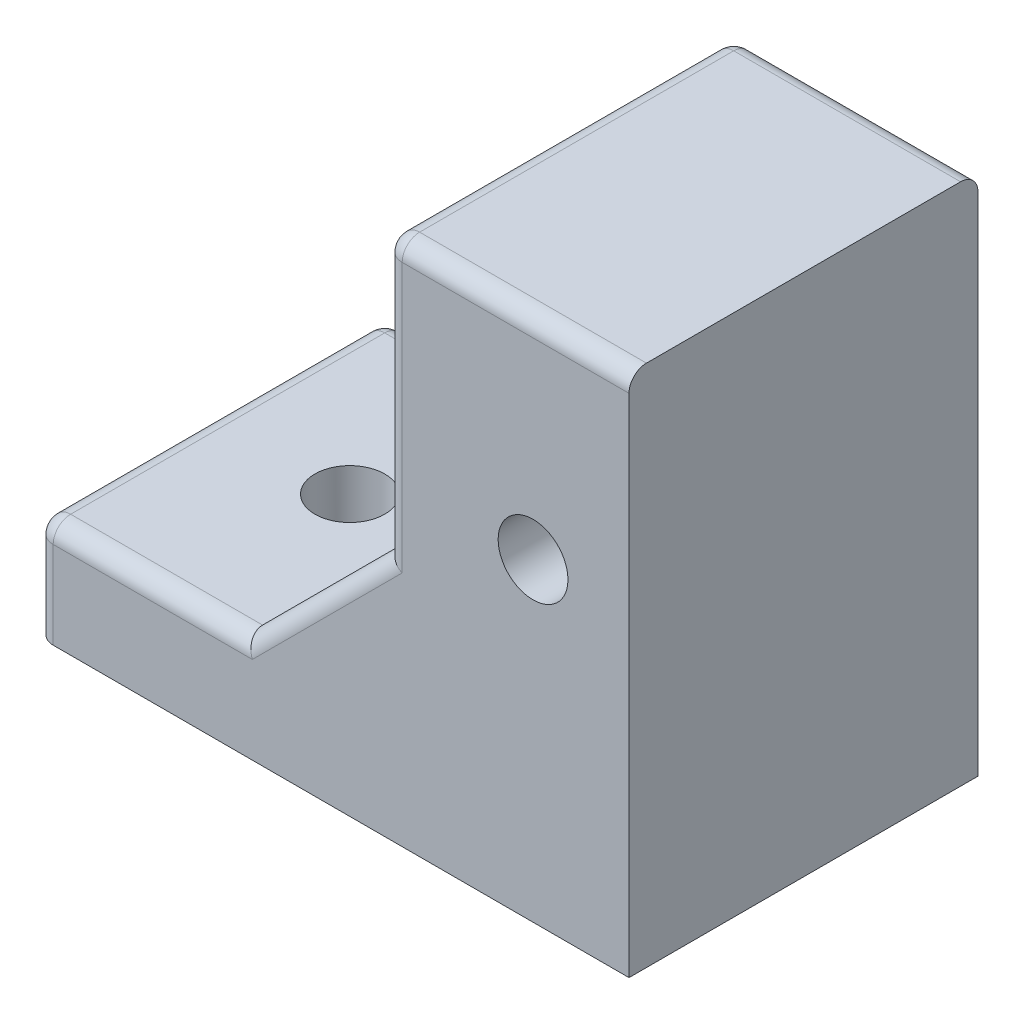
from build123d import *

# Parameters (mm, degrees)
ESQUISSE2_W                  = 7
ESQUISSE2_H                  = 10
BOSS_EXTRU_1_DEPTH           = 15
ESQUISSE3_W                  = 10
ESQUISSE3_H                  = 3
BOSS_EXTRU_2_DEPTH           = 10
BOSS_EXTRU_3_DEPTH           = 2
ESQUISSE7_R                  = 1
ENL_V_MAT_EXTRU_1_DEPTH      = 13
ENL_V_MAT_EXTRU_1_DEPTH_BACK = 4
ESQUISSE8_R                  = 1
ENL_V_MAT_EXTRU_2_DEPTH      = 1
ENL_V_MAT_EXTRU_2_DEPTH_BACK = 11
CONG_1_R                     = 0.5


with BuildPart() as part:
    # Esquisse2 → Boss.-Extru.1 (new body)
    with BuildSketch(Plane(origin=(0, 0, 0), x_dir=(1, 0, 0), z_dir=(0, 1, 0))):
        Rectangle(ESQUISSE2_W, ESQUISSE2_H)
    extrude(amount=BOSS_EXTRU_1_DEPTH)

    # Esquisse3 → Boss.-Extru.2 (add)
    with BuildSketch(Plane.ZY.offset(3.5)):
        with Locations((0, 1.5)):
            Rectangle(ESQUISSE3_W, ESQUISSE3_H)
    extrude(amount=BOSS_EXTRU_2_DEPTH)

    # Esquisse6 → Boss.-Extru.3 (add)
    with BuildSketch(Plane.XY.offset(5)):
        Polygon((-7.5, 3), (-3.5, 7), (-3.5, 3), align=None)
    boss_extru_3 = extrude(amount=-BOSS_EXTRU_3_DEPTH)

    # Symétrie1: Boss.-Extru.3 across plane
    add(boss_extru_3.mirror(Plane.XY))

    # Esquisse7 → Enlèv. mat.-Extru.1 (cut, two sides)
    with BuildSketch(Plane(origin=(0, 3, 0), x_dir=(1, 0, 0), z_dir=(0, 1, 0))) as enl_v_mat_extru_1_sk:
        with Locations((-9.5, 0)):
            Circle(ESQUISSE7_R)
    extrude(amount=ENL_V_MAT_EXTRU_1_DEPTH, mode=Mode.SUBTRACT)
    extrude(enl_v_mat_extru_1_sk.sketch, amount=-ENL_V_MAT_EXTRU_1_DEPTH_BACK, mode=Mode.SUBTRACT)

    # Esquisse8 → Enlèv. mat.-Extru.2 (cut, two sides)
    with BuildSketch(Plane.XY.offset(5)) as enl_v_mat_extru_2_sk:
        with Locations((0.75, 9)):
            Circle(ESQUISSE8_R)
    extrude(amount=ENL_V_MAT_EXTRU_2_DEPTH, mode=Mode.SUBTRACT)
    extrude(enl_v_mat_extru_2_sk.sketch, amount=-ENL_V_MAT_EXTRU_2_DEPTH_BACK, mode=Mode.SUBTRACT)

    # Congé1
    cong_1_edges = [part.edges().sort_by_distance(p)[0] for p in [
        (0, 15, -5),
        (-10.5, 3, -5),
        (-10.5, 3, 5),
        (-13.5, 1.5, -5),
        (-13.5, 1.5, 5),
        (-13.5, 3, 0),
        (-5.5, 5, 5),
        (-3.5, 15, 0),
        (-5.5, 5, -5),
        (0, 15, 5),
        (-3.5, 11, -5),
        (-3.5, 11, 5),
    ]]
    fillet(cong_1_edges, radius=CONG_1_R)


solid = part.part
